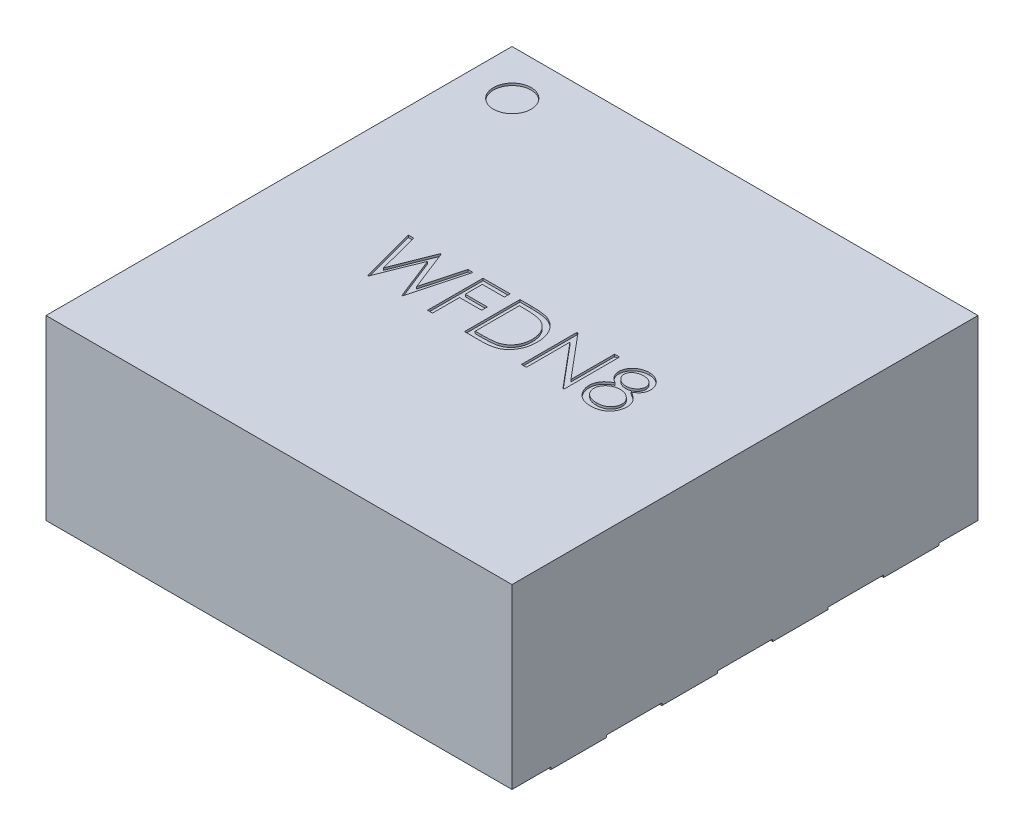
from build123d import *

# Parameters (mm, degrees)
SKETCH1_W           = 2.1
SKETCH1_H           = 2.1
BOSS_EXTRUDE1_DEPTH = 0.8
SKETCH2_W           = 0.3
SKETCH2_H           = 0.25
BOSS_EXTRUDE2_DEPTH = 0.01
SKETCH3_R           = 0.084804816
CUT_EXTRUDE1_DEPTH  = 0.01


with BuildPart() as part:
    # Sketch1 → Boss-Extrude1 (new body)
    with BuildSketch(Plane(origin=(0, 0, 0), x_dir=(1, 0, 0), z_dir=(0, 1, 0))):
        Rectangle(SKETCH1_W, SKETCH1_H)
    extrude(amount=BOSS_EXTRUDE1_DEPTH)

    # Sketch2 → Boss-Extrude2 (add)
    with BuildSketch(Plane.XZ):
        with Locations((-0.9, -0.75)):
            Rectangle(SKETCH2_W, SKETCH2_H)
        with Locations((-0.9, -0.25)):
            Rectangle(SKETCH2_W, SKETCH2_H)
        with Locations((-0.9, 0.25)):
            Rectangle(SKETCH2_W, SKETCH2_H)
        with Locations((-0.9, 0.75)):
            Rectangle(SKETCH2_W, SKETCH2_H)
        with Locations((0.9, 0.75)):
            Rectangle(SKETCH2_W, SKETCH2_H)
        with Locations((0.9, 0.25)):
            Rectangle(SKETCH2_W, SKETCH2_H)
        with Locations((0.9, -0.25)):
            Rectangle(SKETCH2_W, SKETCH2_H)
        with Locations((0.9, -0.75)):
            Rectangle(SKETCH2_W, SKETCH2_H)
        Polygon((-0.45, 0.8), (-0.45, -0.573252578), (-0.095600355, -0.8), (0.45, -0.8), (0.45, 0.8), align=None)
    extrude(amount=BOSS_EXTRUDE2_DEPTH)

    # Sketch3 → Cut-Extrude1 (cut)
    with BuildSketch(Plane(origin=(0, 0.8, 0), x_dir=(1, 0, 0), z_dir=(0, 1, 0))):
        with Locations(Location((-0.846767468, 0.848061669, 0), (0, 0, 270))):
            Circle(SKETCH3_R)
        Polygon((-0.547426031, 0.080370376), (-0.524238931, 0.080370376), (-0.475310646, -0.102972973), (-0.40254422, 0.080370376), (-0.399289011, 0.080370376), (-0.327874749, -0.10172097), (-0.278696063, 0.080370376), (-0.255759364, 0.080370376), (-0.323167216, -0.169629624), (-0.326372345, -0.169629624), (-0.401592697, 0.021576306), (-0.477714492, -0.169629624), (-0.48091962, -0.169629624), align=None)
        Polygon((-0.210887569, 0.080370376), (-0.089092697, 0.080370376), (-0.089092697, 0.05472935), (-0.188451672, 0.05472935), (-0.188451672, -0.022193726), (-0.089092697, -0.022193726), (-0.089092697, -0.047834752), (-0.188451672, -0.047834752), (-0.188451672, -0.169629624), (-0.210887569, -0.169629624), align=None)
        with BuildLine():
            Line((-0.044220902, -0.169629624), (-0.044220902, 0.080370376))
            Line((-0.044220902, 0.080370376), (0.006259867, 0.080370376))
            add(Edge.make_bspline(
                [(0.006259867, 0.080370376), (0.010650509, 0.080338764), (0.019133206, 0.080277689), (0.031391238, 0.079890447), (0.042732936, 0.079205414), (0.053120997, 0.078207591), (0.062583941, 0.076982374), (0.07109527, 0.075446631), (0.078698994, 0.07363319), (0.083375383, 0.072087086), (0.08558679, 0.071355953)],
                knots=[0, 0, 0, 0, 1.314313732, 2.53924729, 3.670748893, 4.714932338, 5.66265055, 6.526160246, 7.303039223, 8, 8, 8, 8], degree=3))
            add(Edge.make_bspline(
                [(0.08558679, 0.071355953), (0.088479271, 0.07025376), (0.094198642, 0.068074367), (0.102342008, 0.063963203), (0.110008105, 0.059305124), (0.117238044, 0.054093991), (0.123866675, 0.048182252), (0.130152953, 0.041821032), (0.135839719, 0.034779007), (0.141047455, 0.027202222), (0.145742859, 0.019179933), (0.149824227, 0.010727425), (0.153213798, 0.001887625), (0.1560276, -0.007314886), (0.158245204, -0.016900341), (0.159758199, -0.026879903), (0.160756127, -0.037214131), (0.160856417, -0.044226593), (0.160907303, -0.047784672)],
                knots=[0, 0, 0, 0, 0.984719456, 1.947108742, 2.898477687, 3.838006223, 4.779231079, 5.722358779, 6.681677486, 7.655904652, 8.64651281, 9.637519902, 10.640069247, 11.656948941, 12.698408672, 13.768548281, 14.867775369, 16, 16, 16, 16], degree=3))
            add(Edge.make_bspline(
                [(0.160907303, -0.047784672), (0.160862377, -0.05087476), (0.160773845, -0.056964102), (0.159978894, -0.065938452), (0.158823442, -0.074646564), (0.157034571, -0.083046972), (0.154862963, -0.091213273), (0.152079809, -0.099058433), (0.148891559, -0.10665442), (0.145173711, -0.113898525), (0.141092183, -0.120761623), (0.136712059, -0.127231304), (0.132038009, -0.133215248), (0.127025464, -0.138731577), (0.121739198, -0.143771976), (0.116144603, -0.148378548), (0.110227243, -0.152461159), (0.10401362, -0.156180239), (0.097322468, -0.15942455), (0.090027049, -0.16216955), (0.08209625, -0.164444309), (0.073549539, -0.16634223), (0.064372148, -0.167847751), (0.054555079, -0.168856779), (0.044113415, -0.169539132), (0.036943468, -0.169598874), (0.033253056, -0.169629624)],
                knots=[0, 0, 0, 0, 1.105936401, 2.179363191, 3.223086493, 4.248585256, 5.251745608, 6.245858792, 7.225916811, 8.198733463, 9.158002045, 10.082870192, 10.993790845, 11.873723703, 12.748670949, 13.606408763, 14.465103618, 15.319838547, 16.196477973, 17.123216899, 18.106603292, 19.147568657, 20.255746949, 21.433717677, 22.679120308, 24, 24, 24, 24], degree=3))
            Line((0.033253056, -0.169629624), (-0.044220902, -0.169629624))
        make_face()
        with BuildLine():
            Line((-0.021785005, -0.143988598), (0.006910909, -0.143988598))
            add(Edge.make_bspline(
                [(0.006910909, -0.143988598), (0.011034364, -0.143970877), (0.018965278, -0.143936793), (0.03036942, -0.143637707), (0.040789377, -0.143148997), (0.050226628, -0.142465063), (0.058675844, -0.141560162), (0.066154683, -0.14055124), (0.07263863, -0.139294279), (0.076562162, -0.138154925), (0.078375251, -0.137628422)],
                knots=[0, 0, 0, 0, 1.375205317, 2.645023457, 3.804390687, 4.853969522, 5.800190428, 6.637939096, 7.370582563, 8, 8, 8, 8], degree=3))
            add(Edge.make_bspline(
                [(0.078375251, -0.137628422), (0.080657277, -0.136824739), (0.085166823, -0.13523657), (0.091658329, -0.132339594), (0.097712401, -0.128908018), (0.103434545, -0.125093569), (0.108743592, -0.120761712), (0.113702458, -0.116006641), (0.118301158, -0.110804158), (0.12249218, -0.105160717), (0.126242773, -0.099111446), (0.129490718, -0.092715815), (0.132337256, -0.0860439), (0.134571441, -0.078993246), (0.136322554, -0.071626885), (0.137562889, -0.063944298), (0.138335369, -0.055946921), (0.138425473, -0.050507483), (0.138471405, -0.047734592)],
                knots=[0, 0, 0, 0, 0.998632004, 1.973411704, 2.929992603, 3.868527914, 4.809262121, 5.754881198, 6.702106254, 7.672490631, 8.653608572, 9.636854334, 10.631411391, 11.644891563, 12.686317036, 13.754757253, 14.855430412, 16, 16, 16, 16], degree=3))
            add(Edge.make_bspline(
                [(0.138471405, -0.047734592), (0.138434742, -0.044810772), (0.138362716, -0.039066902), (0.137457409, -0.030638995), (0.13613444, -0.022533234), (0.13422132, -0.014749077), (0.1317834, -0.007271338), (0.128740925, -0.000141373), (0.125264738, 0.006716118), (0.121128786, 0.013142858), (0.116599101, 0.019220938), (0.111572109, 0.024789146), (0.106127678, 0.029860167), (0.100325189, 0.034512975), (0.09400111, 0.038560381), (0.087304418, 0.042180858), (0.08013687, 0.045253422), (0.075150249, 0.046887626), (0.072616037, 0.047718133)],
                knots=[0, 0, 0, 0, 1.122418816, 2.205001699, 3.251619955, 4.274784885, 5.280384055, 6.268708349, 7.249350384, 8.229342522, 9.199999885, 10.157847722, 11.105861043, 12.055065948, 13.010012805, 13.98527497, 14.976112212, 16, 16, 16, 16], degree=3))
            add(Edge.make_bspline(
                [(0.072616037, 0.047718133), (0.070519526, 0.048297877), (0.06606177, 0.049530574), (0.058787522, 0.050875243), (0.050600726, 0.052061279), (0.041465033, 0.053065425), (0.031390857, 0.053785948), (0.020370451, 0.054326756), (0.008399051, 0.054691515), (0.000100298, 0.054716423), (-0.00420688, 0.05472935)],
                knots=[0, 0, 0, 0, 0.674548936, 1.434276114, 2.292660221, 3.240891867, 4.284742987, 5.42552168, 6.663806718, 8, 8, 8, 8], degree=3))
            Line((-0.00420688, 0.05472935), (-0.021785005, 0.05472935))
            Line((-0.021785005, 0.05472935), (-0.021785005, -0.143988598))
        make_face(mode=Mode.SUBTRACT)
        Polygon((0.212189354, -0.169629624), (0.212189354, 0.080370376), (0.216896886, 0.080370376), (0.382061149, -0.116394448), (0.382061149, 0.080370376), (0.404497046, 0.080370376), (0.404497046, -0.169629624), (0.399388873, -0.169629624), (0.234625251, 0.026684479), (0.234625251, -0.169629624), align=None)
        with BuildLine():
            add(Edge.make_bspline(
                [(0.567708184, -0.030356787), (0.569754509, -0.031423784), (0.573745526, -0.033504784), (0.579429612, -0.036855558), (0.584624255, -0.040387055), (0.589473581, -0.043932474), (0.593892392, -0.047627592), (0.597831278, -0.051487103), (0.601387537, -0.05541467), (0.60448945, -0.059476802), (0.607217795, -0.063662705), (0.609575805, -0.067983368), (0.61159132, -0.07242932), (0.613188672, -0.077049094), (0.614504515, -0.081774827), (0.615409915, -0.08666754), (0.615896838, -0.091694993), (0.615988896, -0.095092728), (0.616035508, -0.096813117)],
                knots=[0, 0, 0, 0, 1.272397273, 2.481599622, 3.635517121, 4.734568067, 5.792894095, 6.808321871, 7.773003508, 8.711915296, 9.623354172, 10.525449501, 11.423591555, 12.311487226, 13.218079475, 14.126165749, 15.051214107, 16, 16, 16, 16], degree=3))
            add(Edge.make_bspline(
                [(0.616035508, -0.096813117), (0.615980406, -0.099220098), (0.61587134, -0.103984417), (0.614921341, -0.111016282), (0.613498985, -0.117845695), (0.611421877, -0.124471158), (0.608728064, -0.130856114), (0.60540829, -0.137006026), (0.601650347, -0.143021691), (0.59863233, -0.146723077), (0.597105219, -0.14859597)],
                knots=[0, 0, 0, 0, 1.025265484, 2.029385089, 3.018602448, 3.995076438, 4.983346944, 5.966715145, 6.97116228, 8, 8, 8, 8], degree=3))
            add(Edge.make_bspline(
                [(0.597105219, -0.14859597), (0.5951169, -0.15078124), (0.591164831, -0.155124775), (0.584394622, -0.160764118), (0.576964487, -0.165503361), (0.568903178, -0.169365639), (0.560232242, -0.172371772), (0.550953527, -0.174531952), (0.541048945, -0.175769268), (0.534241411, -0.175948124), (0.53074905, -0.17603988)],
                knots=[0, 0, 0, 0, 0.954267603, 1.896743057, 2.838368354, 3.796610408, 4.779680527, 5.799409237, 6.871065594, 8, 8, 8, 8], degree=3))
            add(Edge.make_bspline(
                [(0.53074905, -0.17603988), (0.52739095, -0.17595756), (0.52085643, -0.175797374), (0.511345153, -0.174712058), (0.50247922, -0.172810067), (0.494207079, -0.170206881), (0.486578601, -0.166820436), (0.479615523, -0.16260555), (0.473217382, -0.157731875), (0.467578348, -0.152059441), (0.46257203, -0.145983879), (0.458174312, -0.139715907), (0.454519021, -0.133254953), (0.451424229, -0.126697355), (0.449055084, -0.119951201), (0.447414212, -0.1130512), (0.446372118, -0.106009404), (0.446233466, -0.101257143), (0.446163713, -0.098866403)],
                knots=[0, 0, 0, 0, 1.256902934, 2.445805442, 3.576955095, 4.645999104, 5.686449165, 6.692658513, 7.68621702, 8.689161843, 9.678783111, 10.630372946, 11.551080876, 12.453998257, 13.34127905, 14.221779781, 15.105423033, 16, 16, 16, 16], degree=3))
            add(Edge.make_bspline(
                [(0.446163713, -0.098866403), (0.44620499, -0.097112175), (0.446286569, -0.093645201), (0.446851201, -0.088523106), (0.447758948, -0.083537668), (0.448991766, -0.078670472), (0.450662554, -0.073956953), (0.452679849, -0.069374776), (0.455032131, -0.064918769), (0.457752215, -0.060564563), (0.460916645, -0.056373169), (0.464499763, -0.052273455), (0.468573182, -0.048329036), (0.473091586, -0.04449172), (0.478003339, -0.040693436), (0.48343602, -0.037139456), (0.48924561, -0.033578173), (0.493374568, -0.031449006), (0.495492639, -0.030356787)],
                knots=[0, 0, 0, 0, 0.941657376, 1.861047343, 2.762797495, 3.66048619, 4.553285746, 5.444104102, 6.34607688, 7.256116206, 8.197091036, 9.162375105, 10.176350973, 11.237807142, 12.343728897, 13.50695164, 14.721116704, 16, 16, 16, 16], degree=3))
            add(Edge.make_bspline(
                [(0.495492639, -0.030356787), (0.492593255, -0.028775732), (0.486979237, -0.025714368), (0.479545705, -0.020089596), (0.473160661, -0.013997609), (0.467999609, -0.007309767), (0.463937307, -0.00023499), (0.461150264, 0.007182457), (0.459264801, 0.014805036), (0.459078028, 0.020012622), (0.458984226, 0.022627988)],
                knots=[0, 0, 0, 0, 1.166880483, 2.259407225, 3.286803203, 4.280235371, 5.237608625, 6.161067461, 7.076446754, 8, 8, 8, 8], degree=3))
            add(Edge.make_bspline(
                [(0.458984226, 0.022627988), (0.459101042, 0.0252921), (0.459335862, 0.030647428), (0.461234671, 0.038619294), (0.464328961, 0.046449049), (0.468537604, 0.054098742), (0.473779548, 0.061309472), (0.480068587, 0.067776682), (0.487254537, 0.073441788), (0.495301527, 0.078197229), (0.503961258, 0.082067491), (0.513098096, 0.084737378), (0.522552845, 0.086482815), (0.528988397, 0.086680433), (0.532251453, 0.086780633)],
                knots=[0, 0, 0, 0, 0.888701115, 1.786444228, 2.72001202, 3.692817113, 4.693886446, 5.687152267, 6.695133018, 7.739871481, 8.800368666, 9.853104506, 10.91144658, 12, 12, 12, 12], degree=3))
            add(Edge.make_bspline(
                [(0.532251453, 0.086780633), (0.535430297, 0.086677322), (0.541698615, 0.086473606), (0.550912517, 0.084774544), (0.55972858, 0.081936721), (0.568116401, 0.078086919), (0.575925821, 0.073344995), (0.582825985, 0.067602075), (0.58892117, 0.061163393), (0.593962912, 0.05395485), (0.598117404, 0.04633455), (0.601010326, 0.038361513), (0.602864038, 0.030208009), (0.60309785, 0.024691009), (0.603214995, 0.021926866)],
                knots=[0, 0, 0, 0, 1.072916533, 2.115669174, 3.151510826, 4.193348718, 5.225979165, 6.227137561, 7.216255879, 8.211077061, 9.189680878, 10.138522389, 11.067357538, 12, 12, 12, 12], degree=3))
            add(Edge.make_bspline(
                [(0.603214995, 0.021926866), (0.603112526, 0.019214248), (0.602911284, 0.013886818), (0.601218431, 0.006120638), (0.59836748, -0.001152364), (0.59447504, -0.008014718), (0.589401791, -0.014341968), (0.583215453, -0.020214573), (0.575965347, -0.025680775), (0.570518141, -0.028765515), (0.567708184, -0.030356787)],
                knots=[0, 0, 0, 0, 0.975232327, 1.915300861, 2.843280834, 3.77672583, 4.742871857, 5.749627742, 6.839139064, 8, 8, 8, 8], degree=3))
        make_face()
        with BuildLine():
            add(Edge.make_bspline(
                [(0.53099945, 0.061139607), (0.529245821, 0.061093075), (0.525814956, 0.06100204), (0.520784337, 0.060526423), (0.516000596, 0.059601193), (0.511413753, 0.058369856), (0.507086695, 0.056706429), (0.502960656, 0.054749642), (0.499105856, 0.052370637), (0.495475763, 0.049701981), (0.492207851, 0.046766773), (0.489307526, 0.04370865), (0.486898375, 0.040467551), (0.484852581, 0.037124096), (0.483368187, 0.033579055), (0.482256451, 0.029941114), (0.481504923, 0.026164301), (0.48144861, 0.023583122), (0.481420123, 0.022277427)],
                knots=[0, 0, 0, 0, 1.203892937, 2.355340988, 3.463153438, 4.544400666, 5.610487187, 6.640501085, 7.674077295, 8.714426146, 9.728707835, 10.68524104, 11.601827946, 12.495867327, 13.368432065, 14.231010473, 15.105153427, 16, 16, 16, 16], degree=3))
            add(Edge.make_bspline(
                [(0.481420123, 0.022277427), (0.481469221, 0.020971677), (0.481566245, 0.018391326), (0.482316611, 0.014580907), (0.483434958, 0.010836504), (0.485195719, 0.007247153), (0.487307602, 0.003688342), (0.489914136, 0.000249014), (0.493020495, -0.003082799), (0.496522455, -0.006278759), (0.500337565, -0.009271528), (0.504379283, -0.011869612), (0.508596882, -0.014043477), (0.51294703, -0.01585272), (0.517474062, -0.017259144), (0.522150238, -0.018256905), (0.526976346, -0.018877047), (0.530246387, -0.01895112), (0.531900892, -0.018988598)],
                knots=[0, 0, 0, 0, 0.873023192, 1.725219244, 2.590779336, 3.480155217, 4.391973325, 5.357036234, 6.360879153, 7.436073238, 8.526419356, 9.601555421, 10.645666583, 11.697338044, 12.750135903, 13.812665442, 14.89329948, 16, 16, 16, 16], degree=3))
            add(Edge.make_bspline(
                [(0.531900892, -0.018988598), (0.5340259, -0.018926251), (0.538254926, -0.018802171), (0.544489164, -0.017648516), (0.550550782, -0.015833807), (0.556374989, -0.013350953), (0.561811031, -0.010234677), (0.56665675, -0.006503747), (0.570870814, -0.002244312), (0.574409429, 0.00247732), (0.577152989, 0.007502433), (0.579288833, 0.012545311), (0.580536062, 0.017659756), (0.580698746, 0.021085968), (0.580779098, 0.022778229)],
                knots=[0, 0, 0, 0, 1.076279235, 2.141928126, 3.20205304, 4.278698113, 5.344010996, 6.36967002, 7.368914609, 8.37248503, 9.349703398, 10.264243087, 11.142681841, 12, 12, 12, 12], degree=3))
            add(Edge.make_bspline(
                [(0.580779098, 0.022778229), (0.580741105, 0.023965946), (0.580665695, 0.026323393), (0.580044262, 0.029804705), (0.579017417, 0.033206818), (0.577627197, 0.036557837), (0.575797926, 0.039810747), (0.573629056, 0.043016682), (0.570994448, 0.046103522), (0.56803756, 0.049143204), (0.564684317, 0.051956349), (0.56094118, 0.054430257), (0.556827341, 0.056531139), (0.552342702, 0.058237479), (0.547503778, 0.059519075), (0.542332859, 0.060478814), (0.536786827, 0.061019751), (0.532970416, 0.061098788), (0.53099945, 0.061139607)],
                knots=[0, 0, 0, 0, 0.814439003, 1.616544685, 2.417341072, 3.248991801, 4.09997495, 4.973547432, 5.9003056, 6.880240646, 7.880314356, 8.896779544, 9.951930927, 11.043077905, 12.18215768, 13.381699519, 14.647792085, 16, 16, 16, 16], degree=3))
        make_face(mode=Mode.SUBTRACT)
        with BuildLine():
            add(Edge.make_bspline(
                [(0.532451774, -0.044629624), (0.530228504, -0.04466917), (0.525866989, -0.044746749), (0.519477209, -0.045610285), (0.51334484, -0.046812384), (0.507490559, -0.048636016), (0.501916838, -0.051007193), (0.496593503, -0.053859661), (0.49156128, -0.057231478), (0.486889656, -0.061079808), (0.482623704, -0.065226911), (0.478880968, -0.069617064), (0.475702574, -0.074168673), (0.473143056, -0.078939547), (0.471042218, -0.083828662), (0.469662656, -0.088957776), (0.468778248, -0.094228284), (0.468659488, -0.097811148), (0.46859961, -0.099617605)],
                knots=[0, 0, 0, 0, 1.140299081, 2.23698856, 3.303958914, 4.344563908, 5.37730929, 6.408454204, 7.439741482, 8.480804886, 9.510774543, 10.48932336, 11.43758569, 12.353841022, 13.263987381, 14.161954604, 15.073269652, 16, 16, 16, 16], degree=3))
            add(Edge.make_bspline(
                [(0.46859961, -0.099617605), (0.468696986, -0.101862669), (0.468890177, -0.106316825), (0.470422794, -0.112899902), (0.472882475, -0.119272834), (0.476312848, -0.125383688), (0.480560532, -0.13109441), (0.485783851, -0.13607218), (0.491658196, -0.140495142), (0.498382329, -0.144072323), (0.505727219, -0.146929099), (0.513690914, -0.148897382), (0.522159122, -0.150200343), (0.528006236, -0.150331641), (0.53099945, -0.150398855)],
                knots=[0, 0, 0, 0, 0.898778495, 1.783155532, 2.693654817, 3.627872908, 4.583023416, 5.533784346, 6.509005473, 7.520592997, 8.575161974, 9.658835044, 10.801527049, 12, 12, 12, 12], degree=3))
            add(Edge.make_bspline(
                [(0.53099945, -0.150398855), (0.533338762, -0.15035394), (0.537896492, -0.150266431), (0.544545488, -0.149493982), (0.550820099, -0.148269008), (0.556708156, -0.146487327), (0.562275573, -0.144312328), (0.567427956, -0.141514322), (0.57229785, -0.138332014), (0.576645288, -0.134556431), (0.580604803, -0.130522181), (0.584057181, -0.126251464), (0.587054149, -0.121860347), (0.58940636, -0.117249599), (0.591286807, -0.112507676), (0.592638489, -0.107590854), (0.593472504, -0.102484051), (0.593556854, -0.099019832), (0.59359961, -0.097263839)],
                knots=[0, 0, 0, 0, 1.224942928, 2.386581632, 3.501229538, 4.569074225, 5.605009692, 6.626002462, 7.634866581, 8.645888296, 9.63523824, 10.59253846, 11.518950513, 12.414518923, 13.29783783, 14.186679152, 15.080837789, 16, 16, 16, 16], degree=3))
            add(Edge.make_bspline(
                [(0.59359961, -0.097263839), (0.593534907, -0.095558314), (0.593407323, -0.092195318), (0.592597559, -0.087211995), (0.591174997, -0.082397508), (0.58922304, -0.077693936), (0.5866244, -0.073196583), (0.583564052, -0.068788285), (0.579871615, -0.064591396), (0.575699286, -0.060573318), (0.571152218, -0.056857908), (0.56631885, -0.053571162), (0.561236389, -0.050803154), (0.555915588, -0.048551976), (0.550368263, -0.046781442), (0.544598493, -0.045544585), (0.538599523, -0.044766042), (0.534524175, -0.04467561), (0.532451774, -0.044629624)],
                knots=[0, 0, 0, 0, 0.917430815, 1.809013306, 2.70690318, 3.612392954, 4.541220862, 5.495268465, 6.494511384, 7.542276156, 8.608045339, 9.649016899, 10.681629292, 11.715607085, 12.752076957, 13.808767841, 14.885711793, 16, 16, 16, 16], degree=3))
        make_face(mode=Mode.SUBTRACT)
    extrude(amount=-CUT_EXTRUDE1_DEPTH, mode=Mode.SUBTRACT)


solid = part.part
